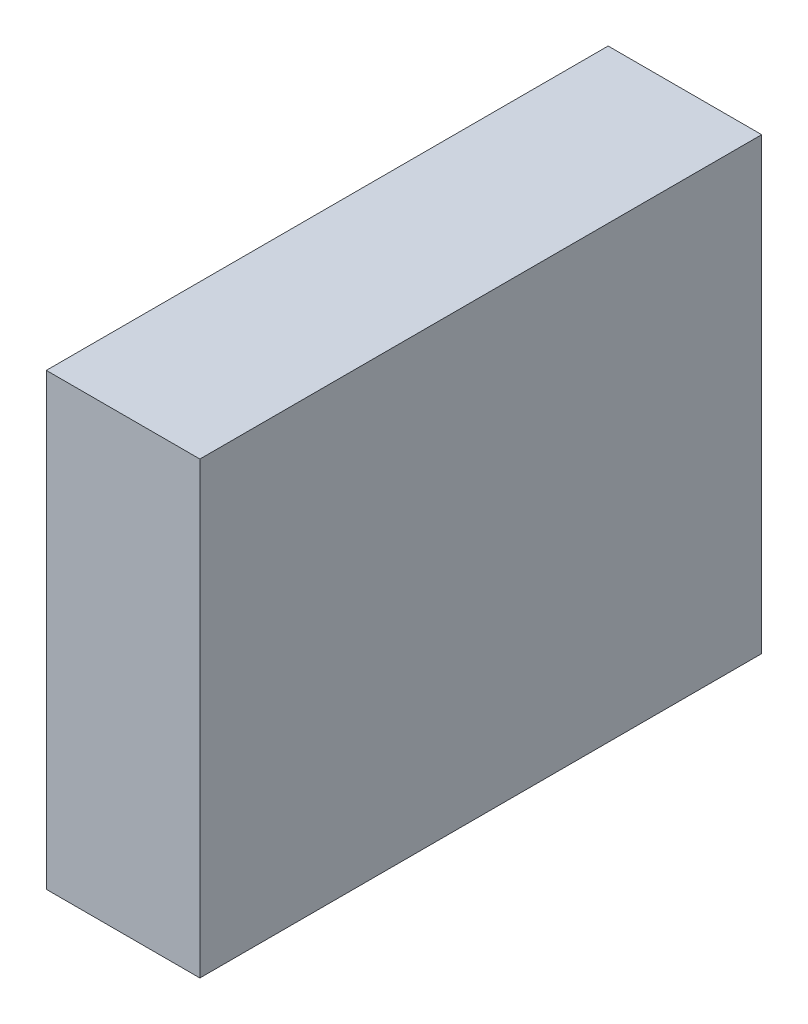
from build123d import *

# Parameters (mm, degrees)
SKETCH1_W           = 15
SKETCH1_H           = 12
BOSS_EXTRUDE1_DEPTH = 4.1


with BuildPart() as part:
    # Sketch1 → Boss-Extrude1 (new body)
    with BuildSketch(Plane(origin=(0, 0, 0), x_dir=(0, 0, -1), z_dir=(1, 0, 0))):
        Rectangle(SKETCH1_W, SKETCH1_H)
    extrude(amount=BOSS_EXTRUDE1_DEPTH)


solid = part.part
